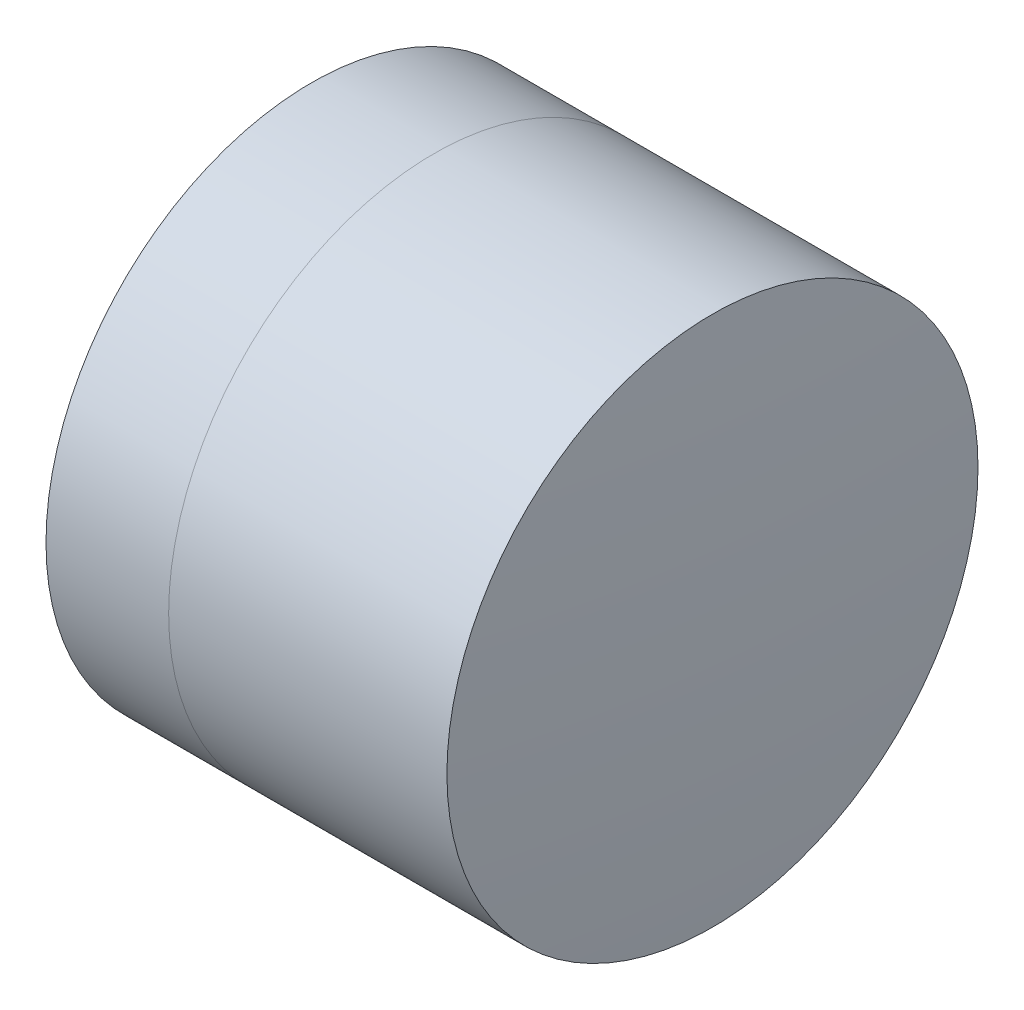
from build123d import *


with BuildPart() as part:
    # 草图1 one side → 旋转1 (revolve)
    with BuildSketch(Plane(origin=(0, 0, 0), x_dir=(1, 0, 0), z_dir=(0, 1, 0)), mode=Mode.PRIVATE) as revolve_1_sk:
        with BuildLine():
            ThreePointArc((257.470802143, 2.5), (256.920675619, 1.303419386), (256.732149058, 0))
            Line((256.732149058, 0), (259.532149058, 0))
            ThreePointArc((259.532149058, 0), (259.298480402, 1.329667055), (258.625474968, 2.5))
            Line((258.625474968, 2.5), (257.470802143, 2.5))
        make_face()
    revolve(revolve_1_sk.sketch.rotate(Axis((124.523309526, 0, 0), (1, 0, 0)), 180), axis=Axis((124.523309526, 0, 0), (1, 0, 0)))  # turned: the seam where the file's is


with BuildPart() as body_2:
    # 草图2 one side → 旋转3 (revolve)
    with BuildSketch(Plane(origin=(0, 0, 0), x_dir=(1, 0, 0), z_dir=(0, 1, 0)), mode=Mode.PRIVATE) as revolve_3_sk:
        with BuildLine():
            Line((261.245238594, 2.5), (258.625474968, 2.5))
            ThreePointArc((258.625474968, 2.5), (259.298480402, 1.329667055), (259.532149058, 0))
            Line((259.532149058, 0), (261.332149058, 0))
            ThreePointArc((261.332149058, 0), (261.310414881, 1.250755115), (261.245238594, 2.5))
        make_face()
    revolve(revolve_3_sk.sketch.rotate(Axis((-0.551919993, 0, 0), (1, 0, 0)), 180), axis=Axis((-0.551919993, 0, 0), (1, 0, 0)))  # turned: the seam where the file's is


solid = Compound([part.part, body_2.part])
